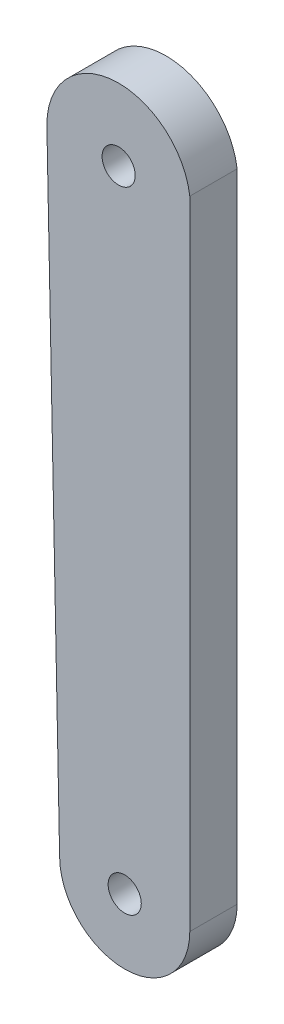
from build123d import *

# Parameters (mm, degrees)
SKETCH1_R           = 1.4
BOSS_EXTRUDE1_DEPTH = 4


with BuildPart() as part:
    # Sketch1 → Boss-Extrude1 (new body)
    with BuildSketch(Plane.XY):
        with BuildLine():
            ThreePointArc((-11.000688459, -8.006682704), (-5.500688459, -13.506682704), (-0.000688459, -8.006682704))
            Line((-0.000688459, -8.006682704), (-0.000688459, 44.219898035))
            Line((-0.000688459, 44.219898035), (-0.000688459, 45.812285407))
            ThreePointArc((-0.000688459, 45.812285407), (-6.411717433, 51.067514262), (-12.077316081, 45.016091721))
            Line((-12.077316081, 45.016091721), (-12.072317389, 44.769911406))
            Line((-12.072317389, 44.769911406), (-11.000688459, -8.006682704))
        make_face()
        with Locations((-5.500688459, -8.006682704)):
            Circle(SKETCH1_R, mode=Mode.SUBTRACT)
        with Locations((-6.012756351, 45.016091721)):
            Circle(SKETCH1_R, mode=Mode.SUBTRACT)
    extrude(amount=BOSS_EXTRUDE1_DEPTH)


solid = part.part
